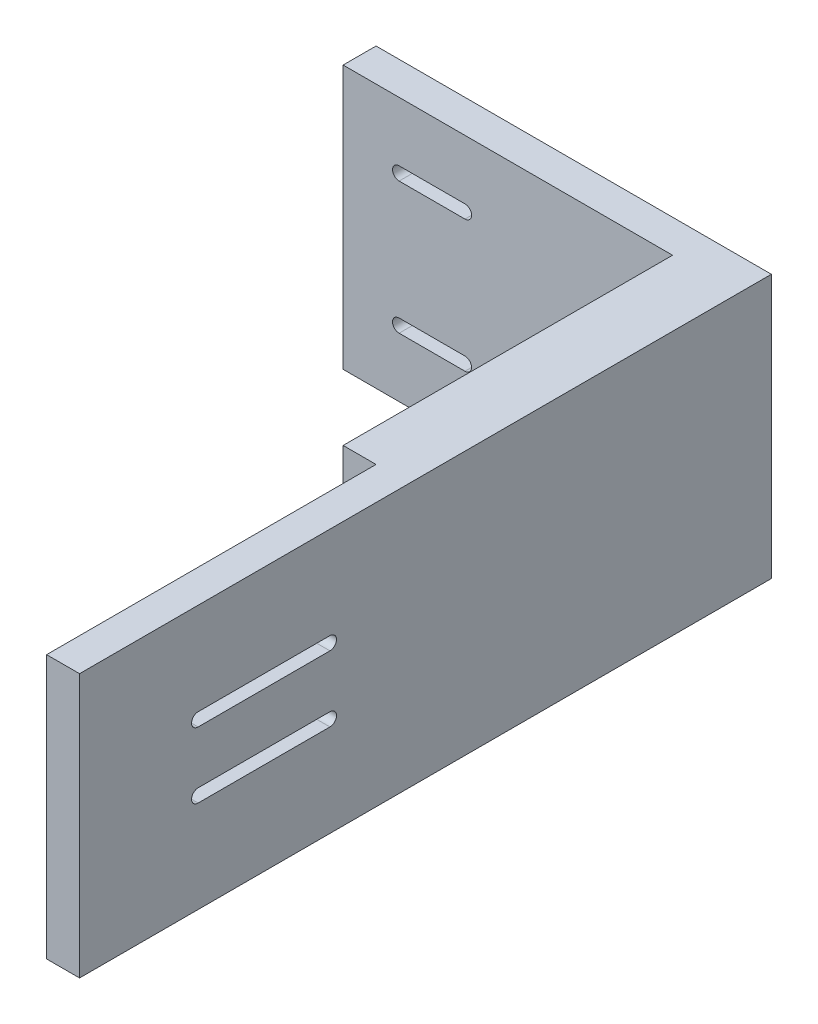
from build123d import *

# Parameters (mm, degrees)
SKETCH_1_W          = 60
SKETCH_1_H          = 40
EXTRUDE_1_DEPTH     = 5
SKETCH_2_W          = 10
SKETCH_2_H          = 40
EXTRUDE_2_DEPTH     = 100
SKETCH_3_R          = 1
EXTRUDE_3_DEPTH     = 2.5
CUT_EXTRUDE_1_DEPTH = 11
SKETCH_5_W          = 5
SKETCH_5_H          = 50
CUT_EXTRUDE_2_DEPTH = 41
CUT_EXTRUDE_3_REACH = 7


with BuildPart() as part:
    # 草图1 → 凸台-拉伸1 (new body)
    with BuildSketch(Plane.XY):
        Rectangle(SKETCH_1_W, SKETCH_1_H)
    extrude(amount=EXTRUDE_1_DEPTH)

    # 草图2 → 凸台-拉伸2 (add)
    with BuildSketch(Plane.XY.offset(5)):
        with Locations((25, 0)):
            Rectangle(SKETCH_2_W, SKETCH_2_H)
    extrude(amount=EXTRUDE_2_DEPTH)

    # 草图3 → 凸台-拉伸3 (add)
    with BuildSketch(Plane.ZY.offset(-20)):
        with Locations((30, 0)):
            Circle(SKETCH_3_R)
    extrude(amount=EXTRUDE_3_DEPTH)

    # 草图4 → 切除-拉伸1 (cut, through all)
    with BuildSketch(Plane.ZY.offset(-20)):
        with BuildLine():
            Line((67, 6), (87, 6))
            ThreePointArc((87, 6), (88, 5), (87, 4))
            Line((87, 4), (67, 4))
            ThreePointArc((67, 4), (66, 5), (67, 6))
        make_face()
        with BuildLine():
            Line((67, -6), (87, -6))
            ThreePointArc((87, -6), (88, -5), (87, -4))
            Line((87, -4), (67, -4))
            ThreePointArc((67, -4), (66, -5), (67, -6))
        make_face()
    extrude(amount=-CUT_EXTRUDE_1_DEPTH, mode=Mode.SUBTRACT)

    # 草图5 → 切除-拉伸2 (cut, through all)
    with BuildSketch(Plane.XZ.offset(20)):
        with Locations((22.5, 80)):
            Rectangle(SKETCH_5_W, SKETCH_5_H)
    extrude(amount=-CUT_EXTRUDE_2_DEPTH, mode=Mode.SUBTRACT)

    # 草图6 → 切除-拉伸3 (cut, up to next)
    with BuildSketch(Plane.XY.offset(5), mode=Mode.PRIVATE) as cut_extrude_3_sk1:
        with BuildLine():
            Line((-11.5, 9.001468336), (-21.5, 9.001468336))
            ThreePointArc((-21.5, 9.001468336), (-22.498531664, 10), (-21.5, 10.998531664))
            Line((-21.5, 10.998531664), (-11.5, 10.998531664))
            ThreePointArc((-11.5, 10.998531664), (-10.501468336, 10), (-11.5, 9.001468336))
        make_face()
    cut_extrude_3_tool1 = extrude(cut_extrude_3_sk1.sketch, amount=-CUT_EXTRUDE_3_REACH, mode=Mode.PRIVATE) & part.part
    add(cut_extrude_3_tool1.solids().sort_by_distance((-16.5, 10, 5))[0], mode=Mode.SUBTRACT)
    # 草图6 → 切除-拉伸3 (cut, up to next)
    with BuildSketch(Plane.XY.offset(5), mode=Mode.PRIVATE) as cut_extrude_3_sk2:
        with BuildLine():
            Line((-11.5, -9.001468336), (-21.5, -9.001468336))
            ThreePointArc((-21.5, -9.001468336), (-22.498531664, -10), (-21.5, -10.998531664))
            Line((-21.5, -10.998531664), (-11.5, -10.998531664))
            ThreePointArc((-11.5, -10.998531664), (-10.501468336, -10), (-11.5, -9.001468336))
        make_face()
    cut_extrude_3_tool2 = extrude(cut_extrude_3_sk2.sketch, amount=-CUT_EXTRUDE_3_REACH, mode=Mode.PRIVATE) & part.part
    add(cut_extrude_3_tool2.solids().sort_by_distance((-16.5, -10, 5))[0], mode=Mode.SUBTRACT)


solid = part.part
